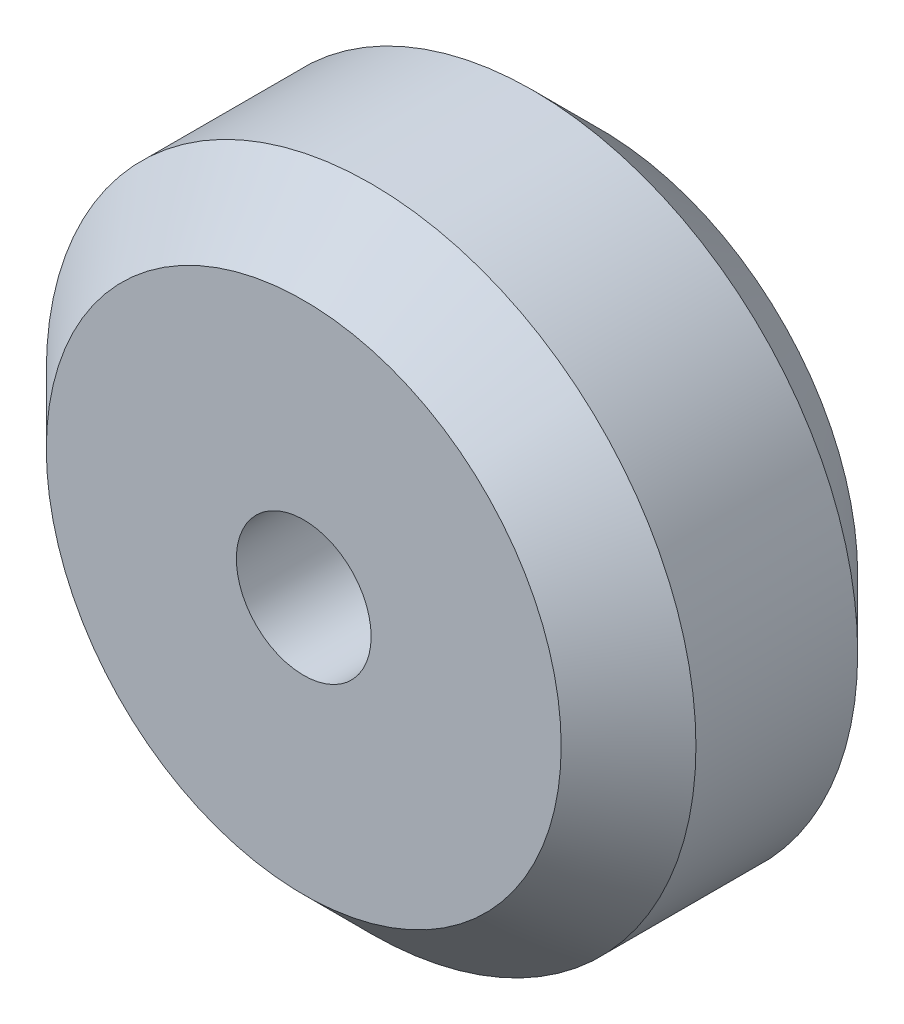
from build123d import *

# Parameters (mm, degrees)
SKETCH1_R           = 12.05
SKETCH1_R_2         = 2.5
BOSS_EXTRUDE1_DEPTH = 11
CHAMFER1_SIZE       = 2.5


with BuildPart() as part:
    # Sketch1 → Boss-Extrude1 (new body)
    with BuildSketch(Plane.XY):
        Circle(SKETCH1_R)
        Circle(SKETCH1_R_2, mode=Mode.SUBTRACT)
    extrude(amount=BOSS_EXTRUDE1_DEPTH)

    # Chamfer1
    chamfer1_edges = [part.edges().sort_by_distance(p)[0] for p in [
        (-12.05, 0, 0),
        (-12.05, 0, 11),
    ]]
    chamfer(chamfer1_edges, length=CHAMFER1_SIZE)


solid = part.part
